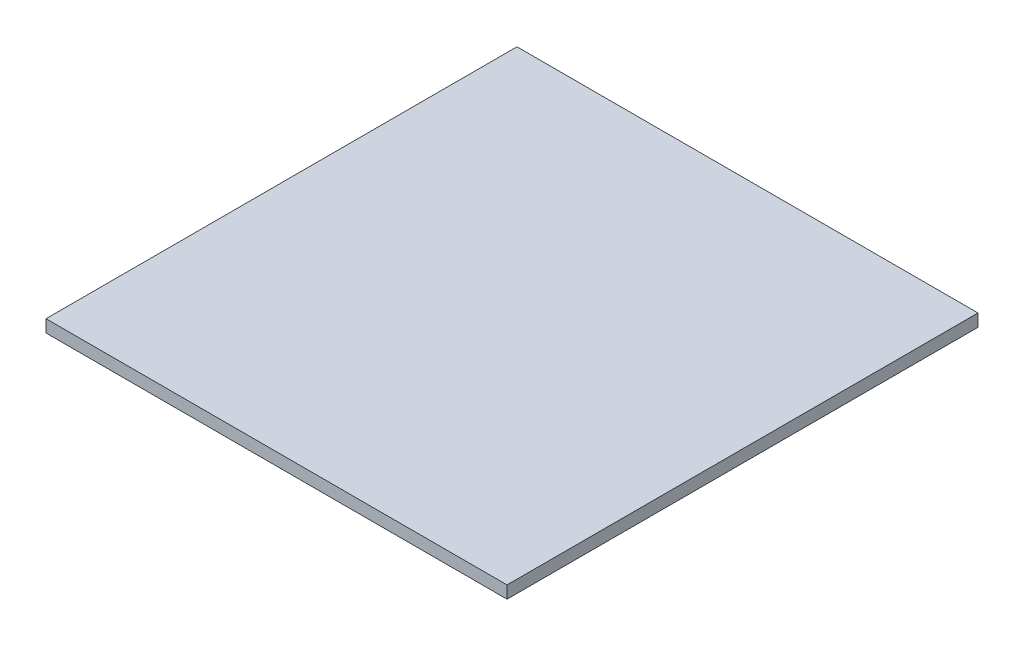
from build123d import *

# Parameters (mm, degrees)
SKETCH1_W           = 590.55
SKETCH1_H           = 603.25
BOSS_EXTRUDE1_DEPTH = 15.875


with BuildPart() as part:
    # Sketch1 → Boss-Extrude1 (new body)
    with BuildSketch(Plane(origin=(0, 0, 0), x_dir=(1, 0, 0), z_dir=(0, 1, 0))):
        with Locations((295.275, 301.625)):
            Rectangle(SKETCH1_W, SKETCH1_H)
    extrude(amount=BOSS_EXTRUDE1_DEPTH)


solid = part.part
